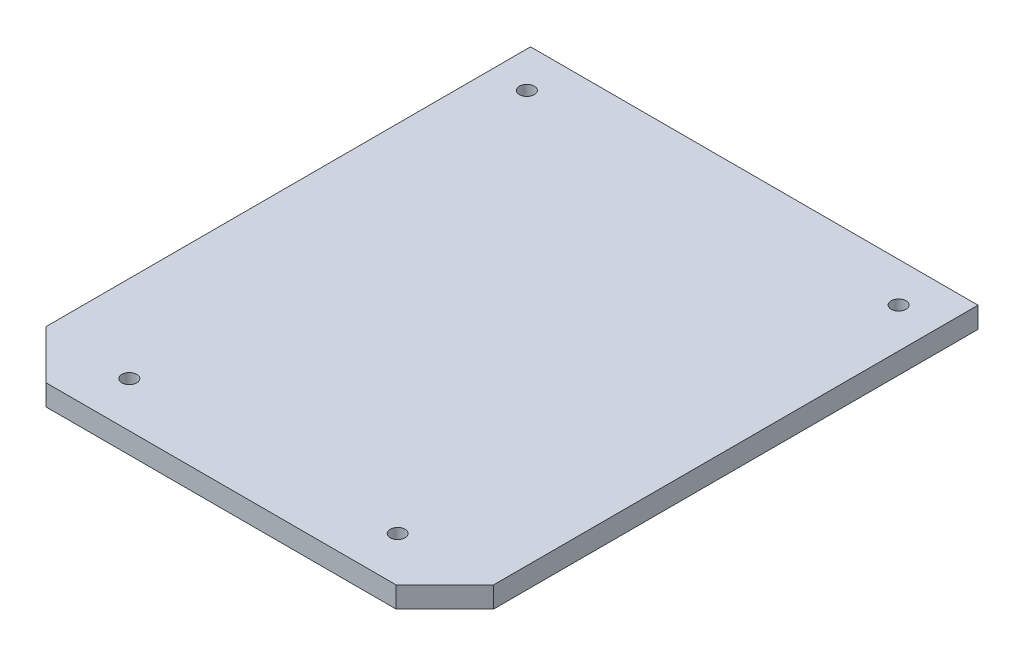
from build123d import *

# Parameters (mm, degrees)
BOSS_EXTRUDE3_DEPTH = 1
SKETCH23_R          = 0.353838886
CUT_EXTRUDE13_DEPTH = 4


with BuildPart() as part:
    # Sketch22 → Boss-Extrude3 (new body)
    with BuildSketch(Plane(origin=(0, 2.015360823, 0), x_dir=(1, 0, 0), z_dir=(0, 1, 0))):
        Polygon((-24.716746523, 29.689845928), (-24.716746523, 6.596637121), (-22.39957081, 4.279461407), (-5.708050839, 4.279461407), (-3.390875125, 6.596637121), (-3.390875125, 29.689845928), align=None)
    extrude(amount=-BOSS_EXTRUDE3_DEPTH)

    # Sketch23 → Cut-Extrude13 (cut)
    with BuildSketch(Plane(origin=(0, 2.015360823, 0), x_dir=(1, 0, 0), z_dir=(0, 1, 0))):
        with Locations((-23.006845426, 27.804561031)):
            Circle(SKETCH23_R)
        with Locations((-5.289134614, 27.804561031)):
            Circle(SKETCH23_R)
        with Locations((-20.585001957, 6.435408141)):
            Circle(SKETCH23_R)
        with Locations((-7.795165685, 6.435408141)):
            Circle(SKETCH23_R)
    extrude(amount=-CUT_EXTRUDE13_DEPTH, mode=Mode.SUBTRACT)


solid = part.part
